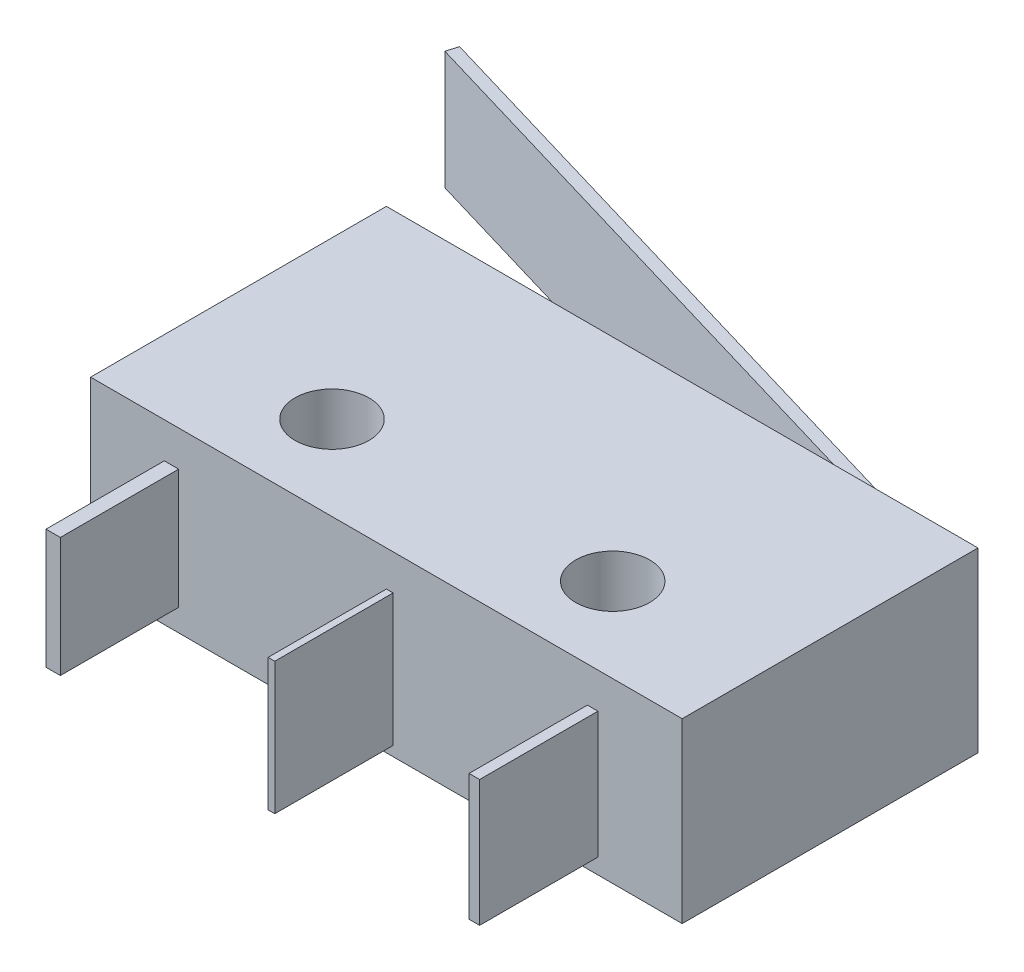
from build123d import *

# Parameters (mm, degrees)
ESBO_O1_W                = 20
ESBO_O1_H                = 10
ESBO_O1_R                = 1.25
RESSALTO_EXTRUS_O1_DEPTH = 6
ESBO_O2_W                = 0.485398366
ESBO_O2_H                = 4.044986381
ESBO_O2_W_2              = 0.226519237
ESBO_O2_H_2              = 4.465664965
ESBO_O2_W_3              = 0.355958801
ESBO_O2_H_3              = 4.271505618
RESSALTO_EXTRUS_O2_DEPTH = 4
EXTRUS_O_FINA1_START     = -1
EXTRUS_O_FINA1_DEPTH     = 4


with BuildPart() as part:
    # Esboço1 → Ressalto-extrusão1 (new body)
    with BuildSketch(Plane(origin=(0, 0, 0), x_dir=(1, 0, 0), z_dir=(0, 1, 0))):
        Rectangle(ESBO_O1_W, ESBO_O1_H)
        with Locations((-4.69, -2.15)):
            Circle(ESBO_O1_R, mode=Mode.SUBTRACT)
        with Locations((4.8, -2.15)):
            Circle(ESBO_O1_R, mode=Mode.SUBTRACT)
    extrude(amount=RESSALTO_EXTRUS_O1_DEPTH)

    # Esboço2 → Ressalto-extrusão2 (add)
    with BuildSketch(Plane.XY.offset(5)):
        with Locations((-7.264795541, 2.773480763)):
            Rectangle(ESBO_O2_W, ESBO_O2_H)
        with Locations((0.113259619, 2.563141471)):
            Rectangle(ESBO_O2_W_2, ESBO_O2_H_2)
        with Locations((6.973556522, 2.660221144)):
            Rectangle(ESBO_O2_W_3, ESBO_O2_H_3)
    extrude(amount=RESSALTO_EXTRUS_O2_DEPTH)


with BuildPart() as body_2:
    # Esboço3 → Extrusão-Fina1 (new body)
    with BuildSketch(Plane(origin=(0, 6, 0), x_dir=(1, 0, 0), z_dir=(0, 1, 0)).offset(EXTRUS_O_FINA1_START)):
        Polygon((7.5, 5), (-14.553426034, 11.530421131), (-14.439853493, 11.913958975), (7.613572541, 5.383537844), align=None)
    extrude(amount=-EXTRUS_O_FINA1_DEPTH)


solid = Compound([part.part, body_2.part])
